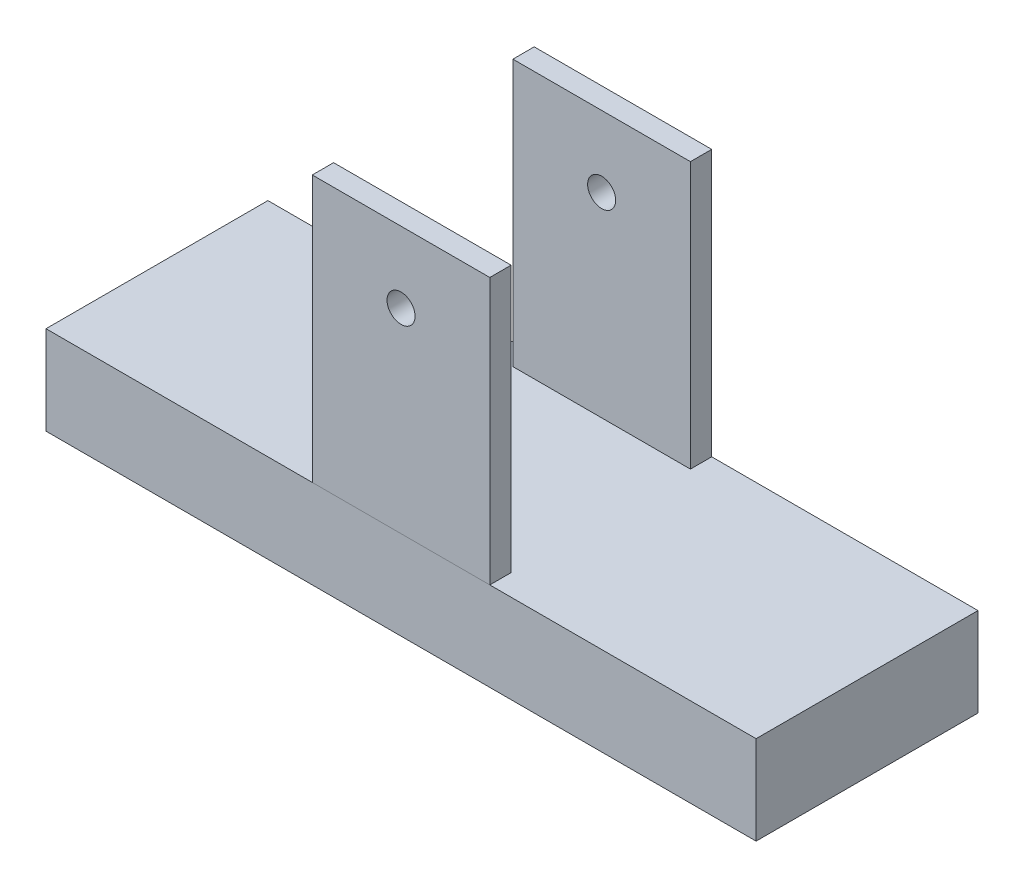
from build123d import *

# Parameters (mm, degrees)
SKETCH1_W               = 400
SKETCH1_H               = 50
BOSS_EXTRUDE1_DEPTH     = 125
SKETCH2_W               = 100
SKETCH2_H               = 12
BOSS_EXTRUDE2_DEPTH     = 150
BOSS_EXTRUDE2_2_DEPTH   = 150
SKETCH3_R               = 7.9
CUT_EXTRUDE1_DEPTH      = 1
CUT_EXTRUDE1_DEPTH_BACK = 126


with BuildPart() as part:
    # Sketch1 → Boss-Extrude1 (new body)
    with BuildSketch(Plane.XY):
        with Locations((-200, 25)):
            Rectangle(SKETCH1_W, SKETCH1_H)
    extrude(amount=-BOSS_EXTRUDE1_DEPTH)


with BuildPart() as body_2:
    # Sketch2 → Boss-Extrude2 (new body)
    with BuildSketch(Plane(origin=(0, 50, 0), x_dir=(1, 0, 0), z_dir=(0, 1, 0))):
        with Locations((-200, 6)):
            Rectangle(SKETCH2_W, SKETCH2_H)
    extrude(amount=BOSS_EXTRUDE2_DEPTH)


with BuildPart() as body_3:
    # Sketch2 → Boss-Extrude2 2 (new body)
    with BuildSketch(Plane(origin=(0, 50, 0), x_dir=(1, 0, 0), z_dir=(0, 1, 0))):
        with Locations((-200, 119)):
            Rectangle(SKETCH2_W, SKETCH2_H)
    extrude(amount=BOSS_EXTRUDE2_2_DEPTH)


with BuildPart() as cut_extrude1_tool:
    # Sketch3 → Cut-Extrude1 (new body, two sides)
    with BuildSketch(Plane.XY) as cut_extrude1_sk:
        with Locations((-200, 160)):
            Circle(SKETCH3_R)
    extrude(amount=CUT_EXTRUDE1_DEPTH)
    extrude(cut_extrude1_sk.sketch, amount=-CUT_EXTRUDE1_DEPTH_BACK)


with BuildPart() as body_2_1:
    add(body_2.part)

    # Cut-Extrude1: cut by cut_extrude1_tool
    add(cut_extrude1_tool.part, mode=Mode.SUBTRACT)


with BuildPart() as body_3_1:
    add(body_3.part)

    # Cut-Extrude1: cut by cut_extrude1_tool
    add(cut_extrude1_tool.part, mode=Mode.SUBTRACT)


solid = Compound([part.part, body_2_1.part, body_3_1.part])
